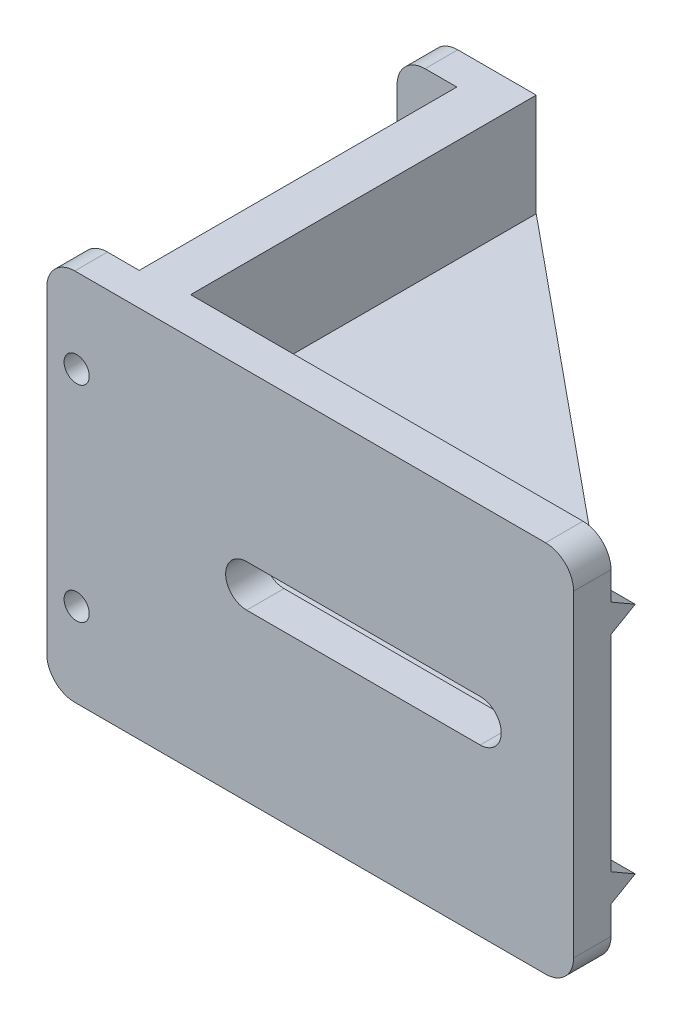
from build123d import *

# Parameters (mm, degrees)
SKETCH_1_W               = 41
SKETCH_1_H               = 40
EXTRUDE_1_DEPTH          = 5
SKETCH_2_W               = 3.5
SKETCH_2_H               = 40
EXTRUDE_2_DEPTH          = 6.4
EXTRUDE_3_DEPTH          = 45
SKETCH_4_W               = 45
SKETCH_4_H               = 4
EXTRUDE_4_DEPTH          = 37
CUT_EXTRUDE_1_DEPTH      = 19
SKETCH_6_R               = 1.35
CUT_EXTRUDE_2_DEPTH      = 42
FILLET_1_R               = 3
FILLET_2_R               = 3
CUT_EXTRUDE_3_DEPTH      = 38
CUT_EXTRUDE_3_DEPTH_BACK = 5


with BuildPart() as part:
    # 스케치1 → 보스-돌출1 (new body)
    with BuildSketch(Plane(origin=(0, 0, 0), x_dir=(0, 0, -1), z_dir=(1, 0, 0))):
        with Locations((20.5, 20)):
            Rectangle(SKETCH_1_W, SKETCH_1_H)
    extrude(amount=EXTRUDE_1_DEPTH)

    # 스케치2 → 보스-돌출2 (add)
    with BuildSketch(Plane.ZY):
        with Locations((-1.75, 20)):
            Rectangle(SKETCH_2_W, SKETCH_2_H)
        with Locations((-39.25, 20)):
            Rectangle(SKETCH_2_W, SKETCH_2_H)
    extrude(amount=EXTRUDE_2_DEPTH)

    # 스케치3 → 보스-돌출3 (add)
    with BuildSketch(Plane(origin=(5, 0, 0), x_dir=(0, 0, -1), z_dir=(1, 0, 0))):
        Polygon((0, 40), (4, 40), (4, 34), (6.598076211, 32.5), (4, 31), (4, 14), (4, 12), (4, 9), (6.598076211, 7.5), (4, 6), (4, 0), (0, 0), align=None)
    extrude(amount=EXTRUDE_3_DEPTH)

    # 스케치4 → 보스-돌출4 (add)
    with BuildSketch(Plane(origin=(0, 0, -4), x_dir=(-1, 0, 0), z_dir=(0, 0, -1))):
        with Locations((-27.5, 27)):
            Rectangle(SKETCH_4_W, SKETCH_4_H)
        with Locations((-27.5, 13)):
            Rectangle(SKETCH_4_W, SKETCH_4_H)
    extrude(amount=EXTRUDE_4_DEPTH)

    # 스케치5 → 컷-돌출1 (cut)
    with BuildSketch(Plane(origin=(0, 29, 0), x_dir=(1, 0, 0), z_dir=(0, 1, 0))):
        Polygon((50, 4), (5, 41), (50, 41), align=None)
    extrude(amount=-CUT_EXTRUDE_1_DEPTH, mode=Mode.SUBTRACT)

    # 스케치6 → 컷-돌출2 (cut, through all)
    with BuildSketch(Plane(origin=(0, 0, -41), x_dir=(-1, 0, 0), z_dir=(0, 0, -1))):
        with Locations((3.2, 9)):
            Circle(SKETCH_6_R)
        with Locations((3.2, 31)):
            Circle(SKETCH_6_R)
    extrude(amount=-CUT_EXTRUDE_2_DEPTH, mode=Mode.SUBTRACT)

    # 필렛1
    fillet_1_edges = [part.edges().sort_by_distance(p)[0] for p in [
        (50, 0, -2),
        (50, 40, -2),
    ]]
    fillet(fillet_1_edges, radius=FILLET_1_R)

    # 필렛2
    fillet_2_edges = [part.edges().sort_by_distance(p)[0] for p in [
        (-6.4, 0, -1.75),
        (-6.4, 40, -1.75),
        (-6.4, 40, -39.25),
        (-6.4, 0, -39.25),
    ]]
    fillet(fillet_2_edges, radius=FILLET_2_R)

    # 스케치7 → 컷-돌출3 (cut, two sides)
    with BuildSketch(Plane(origin=(0, 0, -4), x_dir=(-1, 0, 0), z_dir=(0, 0, -1))) as cut_extrude_3_sk:
        with BuildLine():
            Line((-40, 22.25), (-15, 22.25))
            ThreePointArc((-15, 22.25), (-12.75, 20), (-15, 17.75))
            Line((-15, 17.75), (-40, 17.75))
            ThreePointArc((-40, 17.75), (-42.25, 20), (-40, 22.25))
        make_face()
    extrude(amount=CUT_EXTRUDE_3_DEPTH, mode=Mode.SUBTRACT)
    extrude(cut_extrude_3_sk.sketch, amount=-CUT_EXTRUDE_3_DEPTH_BACK, mode=Mode.SUBTRACT)


solid = part.part
